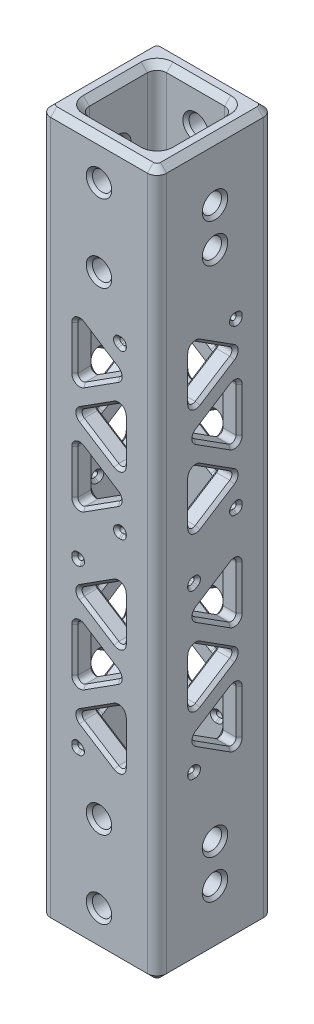
from build123d import *

# Parameters (mm, degrees)
SKETCH1_W                    = 19.05
SKETCH1_H                    = 19.05
SKETCH1_W_2                  = 12.7
SKETCH1_H_2                  = 12.7
BOSS_EXTRUDE1_DEPTH          = 57.94375
F_1_8_0_125_DIAMETER_HOLE1_D = 3.175
F_1_8_0_125_DIAMETER_HOLE2_D = 3.175
F_1_8_0_125_DIAMETER_HOLE3_D = 3.175
CUT_EXTRUDE1_DEPTH           = 10.525
CIRPATTERN2_COUNT            = 4
FILLET1_R                    = 1.5875
FILLET2_R                    = 0.79375
FILLET3_R                    = 0.396875
CHAMFER1_SIZE                = 1.016
CHAMFER2_SIZE                = 0.508


with BuildPart() as part:
    # Sketch1 → Boss-Extrude1 (new body, symmetric)
    with BuildSketch(Plane(origin=(0, 0, 0), x_dir=(1, 0, 0), z_dir=(0, 1, 0))):
        Rectangle(SKETCH1_W, SKETCH1_H)
        Rectangle(SKETCH1_W_2, SKETCH1_H_2, mode=Mode.SUBTRACT)
    extrude(amount=BOSS_EXTRUDE1_DEPTH, both=True)

    # 1_8 _0.125_ Diameter Hole1 (through all)
    with Locations(Plane(origin=(0, 0, 9.525), x_dir=(-1, 0, 0), z_dir=(0, 0, 1))):
        with Locations((0, -51.59375), (0, -38.89375), (0, 38.89375), (0, 51.59375)):
            Hole(F_1_8_0_125_DIAMETER_HOLE1_D / 2)

    # 1_8 _0.125_ Diameter Hole2 (through all)
    with Locations(Plane.ZY.offset(9.525)):
        with Locations((0, 48.41875), (0, 42.06875)):
            Hole(F_1_8_0_125_DIAMETER_HOLE2_D / 2)

    # 1_8 _0.125_ Diameter Hole3 (through all)
    with Locations(Plane(origin=(9.525, 0, 0), x_dir=(0, 0, -1), z_dir=(1, 0, 0))):
        with Locations((0, -42.06875), (0, -48.41875)):
            Hole(F_1_8_0_125_DIAMETER_HOLE3_D / 2)

    # Sketch14 → Cut-Extrude1 (cut, through all)
    with BuildSketch(Plane.XY):
        Polygon((-3.96875, 30.95625), (-1.935718061, 30.95625), (-3.96875, 29.659612075), align=None)
        Polygon((3.96875, 30.95625), (-3.96875, 25.893829025), (3.96875, 20.83140805), align=None)
        Polygon((-3.96875, 22.128045975), (3.96875, 17.065625), (-3.96875, 12.003204025), align=None)
        Polygon((3.96875, 13.29984195), (-3.96875, 8.237420975), (3.96875, 3.175), align=None)
        Polygon((-1.935718061, 3.175), (-3.96875, 3.175), (-3.96875, 4.471637925), align=None)
        Polygon((1.935718061, -3.175), (3.96875, -3.175), (3.96875, -4.471637925), align=None)
        Polygon((-3.96875, -3.175), (3.96875, -8.237420975), (-3.96875, -13.29984195), align=None)
        Polygon((3.96875, -12.003204025), (-3.96875, -17.065625), (3.96875, -22.128045975), align=None)
        Polygon((-3.96875, -30.95625), (3.96875, -25.893829025), (-3.96875, -20.83140805), align=None)
        Polygon((1.935718061, -30.95625), (3.96875, -30.95625), (3.96875, -29.659612075), align=None)
    cut_extrude1 = extrude(amount=-CUT_EXTRUDE1_DEPTH, mode=Mode.SUBTRACT)

    # CirPattern2: Cut-Extrude1 ×4 about axis
    cirpattern2_axis = Axis((0, 0, 0), (0, 1, 0))
    for i in range(1, CIRPATTERN2_COUNT):
        add(cut_extrude1.rotate(cirpattern2_axis, i * 360 / CIRPATTERN2_COUNT), mode=Mode.SUBTRACT)

    # Fillet1
    fillet1_edges = [part.edges().sort_by_distance(p)[0] for p in [
        (6.35, 0, 6.35),
        (6.35, 0, -6.35),
        (-6.35, 0, -6.35),
        (-6.35, 0, 6.35),
        (9.525, 0, 9.525),
        (-9.525, 0, 9.525),
        (-9.525, 0, -9.525),
        (9.525, 0, -9.525),
    ]]
    fillet(fillet1_edges, radius=FILLET1_R)

    # Fillet2
    fillet2_edges = [part.edges().sort_by_distance(p)[0] for p in [
        (3.96875, 30.95625, -7.9375),
        (3.96875, 20.83140805, -7.9375),
        (-3.96875, 25.893829025, -7.9375),
        (-3.96875, 12.003204025, -7.9375),
        (-3.96875, 22.128045975, -7.9375),
        (3.96875, 17.065625, -7.9375),
        (-3.96875, -13.29984195, -7.9375),
        (-3.96875, -3.175, -7.9375),
        (3.96875, -8.237420975, -7.9375),
        (3.96875, 13.29984195, -7.9375),
        (3.96875, 3.175, -7.9375),
        (-3.96875, 8.237420975, -7.9375),
        (-3.96875, -30.95625, -7.9375),
        (-3.96875, -20.83140805, -7.9375),
        (3.96875, -25.893829025, -7.9375),
        (3.96875, -12.003204025, -7.9375),
        (3.96875, -22.128045975, -7.9375),
        (-3.96875, -17.065625, -7.9375),
        (7.9375, -12.003204025, 3.96875),
        (-7.9375, -13.29984195, 3.96875),
        (7.9375, -13.29984195, -3.96875),
        (7.9375, -30.95625, -3.96875),
        (-7.9375, -12.003204025, -3.96875),
        (-7.9375, -30.95625, 3.96875),
        (7.9375, -22.128045975, 3.96875),
        (7.9375, -17.065625, -3.96875),
        (3.96875, -30.95625, 7.9375),
        (3.96875, -20.83140805, 7.9375),
        (-3.96875, -25.893829025, 7.9375),
        (3.96875, -13.29984195, 7.9375),
        (3.96875, -3.175, 7.9375),
        (-3.96875, -8.237420975, 7.9375),
        (7.9375, -20.83140805, -3.96875),
        (7.9375, -25.893829025, 3.96875),
        (7.9375, -3.175, -3.96875),
        (7.9375, -8.237420975, 3.96875),
        (-3.96875, -12.003204025, 7.9375),
        (-3.96875, -22.128045975, 7.9375),
        (3.96875, -17.065625, 7.9375),
        (-7.9375, -20.83140805, 3.96875),
        (-7.9375, -25.893829025, -3.96875),
        (-7.9375, -22.128045975, -3.96875),
        (-7.9375, -17.065625, 3.96875),
        (-7.9375, -3.175, 3.96875),
        (-7.9375, -8.237420975, -3.96875),
        (7.9375, 12.003204025, -3.96875),
        (-7.9375, 13.29984195, -3.96875),
        (7.9375, 13.29984195, 3.96875),
        (7.9375, 30.95625, 3.96875),
        (-7.9375, 30.95625, -3.96875),
        (-7.9375, 12.003204025, 3.96875),
        (7.9375, 3.175, 3.96875),
        (7.9375, 8.237420975, -3.96875),
        (-3.96875, 13.29984195, 7.9375),
        (-3.96875, 3.175, 7.9375),
        (3.96875, 8.237420975, 7.9375),
        (-3.96875, 30.95625, 7.9375),
        (-3.96875, 20.83140805, 7.9375),
        (3.96875, 25.893829025, 7.9375),
        (-7.9375, 20.83140805, -3.96875),
        (-7.9375, 25.893829025, 3.96875),
        (-7.9375, 22.128045975, 3.96875),
        (-7.9375, 17.065625, -3.96875),
        (3.96875, 12.003204025, 7.9375),
        (3.96875, 22.128045975, 7.9375),
        (-3.96875, 17.065625, 7.9375),
        (7.9375, 20.83140805, 3.96875),
        (7.9375, 25.893829025, -3.96875),
        (7.9375, 22.128045975, -3.96875),
        (7.9375, 17.065625, 3.96875),
        (-7.9375, 3.175, -3.96875),
        (-7.9375, 8.237420975, 3.96875),
    ]]
    fillet(fillet2_edges, radius=FILLET2_R)

    # Fillet3
    fillet3_edges = [part.edges().sort_by_distance(p)[0] for p in [
        (3.96875, -3.175, -7.9375),
        (3.96875, -4.471637925, -7.9375),
        (1.935718061, -3.175, -7.9375),
        (-3.96875, 3.175, -7.9375),
        (-3.96875, 4.471637925, -7.9375),
        (-1.935718061, 3.175, -7.9375),
        (3.96875, -29.659612075, -7.9375),
        (3.96875, -30.95625, -7.9375),
        (1.935718061, -30.95625, -7.9375),
        (-3.96875, 29.659612075, -7.9375),
        (-3.96875, 30.95625, -7.9375),
        (-1.935718061, 30.95625, -7.9375),
        (-7.9375, -29.659612075, -3.96875),
        (7.9375, -29.659612075, 3.96875),
        (7.9375, -30.95625, 1.935718061),
        (7.9375, -30.95625, 3.96875),
        (-7.9375, -3.175, -3.96875),
        (7.9375, -3.175, 3.96875),
        (7.9375, -4.471637925, 3.96875),
        (7.9375, -3.175, 1.935718061),
        (-7.9375, -4.471637925, -3.96875),
        (-7.9375, -3.175, -1.935718061),
        (-7.9375, -30.95625, -3.96875),
        (-7.9375, -30.95625, -1.935718061),
        (-3.96875, -3.175, 7.9375),
        (-3.96875, -4.471637925, 7.9375),
        (-1.935718061, -3.175, 7.9375),
        (-3.96875, -29.659612075, 7.9375),
        (-1.935718061, -30.95625, 7.9375),
        (-3.96875, -30.95625, 7.9375),
        (7.9375, 29.659612075, -3.96875),
        (7.9375, 3.175, -3.96875),
        (7.9375, 30.95625, -3.96875),
        (7.9375, 30.95625, -1.935718061),
        (3.96875, 3.175, 7.9375),
        (3.96875, 4.471637925, 7.9375),
        (1.935718061, 3.175, 7.9375),
        (-7.9375, 29.659612075, 3.96875),
        (-7.9375, 30.95625, 3.96875),
        (-7.9375, 30.95625, 1.935718061),
        (3.96875, 29.659612075, 7.9375),
        (3.96875, 30.95625, 7.9375),
        (1.935718061, 30.95625, 7.9375),
        (-7.9375, 3.175, 3.96875),
        (-7.9375, 4.471637925, 3.96875),
        (-7.9375, 3.175, 1.935718061),
        (7.9375, 4.471637925, -3.96875),
        (7.9375, 3.175, -1.935718061),
    ]]
    fillet(fillet3_edges, radius=FILLET3_R)

    # Chamfer1
    chamfer1_edges = [part.edges().sort_by_distance(p)[0] for p in [
        (0, -57.94375, -9.525),
        (0, 57.94375, -9.525),
        (9.525, -57.94375, 0),
        (0, -57.94375, 9.525),
        (-9.525, -57.94375, 0),
        (0, -57.94375, 6.35),
        (6.35, -57.94375, 0),
        (0, -57.94375, -6.35),
        (-6.35, -57.94375, 0),
        (-9.060032015, -57.94375, 9.060032015),
        (-9.060032015, -57.94375, -9.060032015),
        (9.060032015, -57.94375, 9.060032015),
        (9.060032015, -57.94375, -9.060032015),
        (9.525, 57.94375, 0),
        (-9.525, 57.94375, 0),
        (0, 57.94375, 9.525),
        (6.35, 57.94375, 0),
        (0, 57.94375, 6.35),
        (-6.35, 57.94375, 0),
        (0, 57.94375, -6.35),
        (-9.060032015, 57.94375, 9.060032015),
        (-9.060032015, 57.94375, -9.060032015),
        (9.060032015, 57.94375, 9.060032015),
        (9.060032015, 57.94375, -9.060032015),
        (5.885032015, -57.94375, -5.885032015),
        (5.885032015, 57.94375, -5.885032015),
        (5.885032015, -57.94375, 5.885032015),
        (5.885032015, 57.94375, 5.885032015),
        (-5.885032015, -57.94375, 5.885032015),
        (-5.885032015, 57.94375, 5.885032015),
        (-5.885032015, -57.94375, -5.885032015),
        (-5.885032015, 57.94375, -5.885032015),
    ]]
    chamfer(chamfer1_edges, length=CHAMFER1_SIZE)

    # Chamfer2
    chamfer2_edges = [part.edges().sort_by_distance(p)[0] for p in [
        (9.525, -12.548152991, -3.556607903),
        (6.35, 21.376357017, -3.556607903),
        (9.525, 21.376357017, -3.556607903),
        (6.35, 17.065625, 3.286382985),
        (9.525, 17.065625, 3.286382985),
        (6.35, 12.754892983, -3.556607903),
        (9.525, 12.754892983, -3.556607903),
        (6.35, 21.583097009, 3.556607903),
        (9.525, 21.583097009, 3.556607903),
        (6.35, 30.204561042, 3.556607903),
        (9.525, 30.204561042, 3.556607903),
        (6.35, 25.893829025, -3.286382985),
        (9.525, 25.893829025, -3.286382985),
        (3.556607903, -21.376357017, -6.35),
        (3.556607903, -21.376357017, -9.525),
        (-3.286382985, -17.065625, -6.35),
        (-3.286382985, -17.065625, -9.525),
        (3.556607903, -12.754892983, -6.35),
        (3.556607903, -12.754892983, -9.525),
        (-3.556607903, -21.583097009, -6.35),
        (-3.556607903, -21.583097009, -9.525),
        (3.286382985, -25.893829025, -6.35),
        (3.286382985, -25.893829025, -9.525),
        (-3.556607903, -30.204561042, -6.35),
        (-3.556607903, -30.204561042, -9.525),
        (3.556607903, 3.926688958, -6.35),
        (3.556607903, 3.926688958, -9.525),
        (-3.286382985, 8.237420975, -6.35),
        (-3.286382985, 8.237420975, -9.525),
        (3.556607903, 12.548152991, -6.35),
        (3.556607903, 12.548152991, -9.525),
        (-3.556607903, -3.926688958, -6.35),
        (-3.556607903, -3.926688958, -9.525),
        (3.286382985, -8.237420975, -6.35),
        (3.286382985, -8.237420975, -9.525),
        (-3.556607903, -12.548152991, -6.35),
        (-3.556607903, -12.548152991, -9.525),
        (-3.556607903, 21.376357017, -6.35),
        (-3.556607903, 21.376357017, -9.525),
        (3.286382985, 17.065625, -6.35),
        (3.286382985, 17.065625, -9.525),
        (-3.556607903, 12.754892983, -6.35),
        (-3.556607903, 12.754892983, -9.525),
        (3.556607903, 21.583097009, -6.35),
        (3.556607903, 21.583097009, -9.525),
        (3.556607903, 30.204561042, -6.35),
        (3.556607903, 30.204561042, -9.525),
        (-3.286382985, 25.893829025, -6.35),
        (-3.286382985, 25.893829025, -9.525),
        (-3.433961043, -30.95625, 6.35),
        (-3.433961043, -30.95625, 9.525),
        (-3.220550095, -30.136802991, 6.35),
        (-3.220550095, -30.136802991, 9.525),
        (-3.96875, -30.471415503, 6.35),
        (-3.96875, -30.471415503, 9.525),
        (-3.220550095, -3.994447009, 6.35),
        (-3.220550095, -3.994447009, 9.525),
        (-3.433961043, -3.175, 6.35),
        (-3.433961043, -3.175, 9.525),
        (-3.96875, -3.659834497, 6.35),
        (-3.96875, -3.659834497, 9.525),
        (3.220550095, 3.994447009, 6.35),
        (3.220550095, 3.994447009, 9.525),
        (3.433961043, 3.175, 6.35),
        (3.433961043, 3.175, 9.525),
        (3.96875, 3.659834497, 6.35),
        (3.96875, 3.659834497, 9.525),
        (3.220550095, 30.136802991, 6.35),
        (3.220550095, 30.136802991, 9.525),
        (3.96875, 30.471415503, 6.35),
        (3.96875, 30.471415503, 9.525),
        (3.433961043, 30.95625, 6.35),
        (3.433961043, 30.95625, 9.525),
        (-6.35, -30.95625, -3.433961043),
        (-9.525, -30.95625, -3.433961043),
        (-6.35, -30.136802991, -3.220550095),
        (-9.525, -30.136802991, -3.220550095),
        (-6.35, -30.471415503, -3.96875),
        (-9.525, -30.471415503, -3.96875),
        (-6.35, -3.994447009, -3.220550095),
        (-9.525, -3.994447009, -3.220550095),
        (-6.35, -3.175, -3.433961043),
        (-9.525, -3.175, -3.433961043),
        (-6.35, -3.659834497, -3.96875),
        (-9.525, -3.659834497, -3.96875),
        (-6.35, 3.175, 3.433961043),
        (-9.525, 3.175, 3.433961043),
        (-6.35, 3.659834497, 3.96875),
        (-9.525, 3.659834497, 3.96875),
        (-6.35, 3.994447009, 3.220550095),
        (-9.525, 3.994447009, 3.220550095),
        (-6.35, 30.95625, 3.433961043),
        (-9.525, 30.95625, 3.433961043),
        (-6.35, 30.136802991, 3.220550095),
        (-9.525, 30.136802991, 3.220550095),
        (-6.35, 30.471415503, 3.96875),
        (-9.525, 30.471415503, 3.96875),
        (6.35, 30.95625, -3.433961043),
        (9.525, 30.95625, -3.433961043),
        (6.35, 30.136802991, -3.220550095),
        (9.525, 30.136802991, -3.220550095),
        (6.35, 30.471415503, -3.96875),
        (9.525, 30.471415503, -3.96875),
        (6.35, -30.471415503, 3.96875),
        (9.525, -30.471415503, 3.96875),
        (6.35, -30.95625, 3.433961043),
        (9.525, -30.95625, 3.433961043),
        (6.35, -30.136802991, 3.220550095),
        (9.525, -30.136802991, 3.220550095),
        (6.35, 3.659834497, -3.96875),
        (9.525, 3.659834497, -3.96875),
        (6.35, 3.994447009, -3.220550095),
        (9.525, 3.994447009, -3.220550095),
        (6.35, 3.175, -3.433961043),
        (9.525, 3.175, -3.433961043),
        (6.35, -3.659834497, 3.96875),
        (9.525, -3.659834497, 3.96875),
        (6.35, -3.994447009, 3.220550095),
        (9.525, -3.994447009, 3.220550095),
        (6.35, -3.175, 3.433961043),
        (9.525, -3.175, 3.433961043),
        (-3.433961043, 30.95625, -6.35),
        (-3.433961043, 30.95625, -9.525),
        (-3.220550095, 30.136802991, -6.35),
        (-3.220550095, 30.136802991, -9.525),
        (-3.96875, 30.471415503, -6.35),
        (-3.96875, 30.471415503, -9.525),
        (3.96875, -30.471415503, -6.35),
        (3.96875, -30.471415503, -9.525),
        (3.433961043, -30.95625, -6.35),
        (3.433961043, -30.95625, -9.525),
        (3.220550095, -30.136802991, -6.35),
        (3.220550095, -30.136802991, -9.525),
        (-3.96875, 3.659834497, -6.35),
        (-3.96875, 3.659834497, -9.525),
        (-3.220550095, 3.994447009, -6.35),
        (-3.220550095, 3.994447009, -9.525),
        (-3.433961043, 3.175, -6.35),
        (-3.433961043, 3.175, -9.525),
        (3.96875, -3.659834497, -6.35),
        (3.96875, -3.659834497, -9.525),
        (3.220550095, -3.994447009, -6.35),
        (3.220550095, -3.994447009, -9.525),
        (3.433961043, -3.175, -6.35),
        (3.433961043, -3.175, -9.525),
        (-2.915055546, -30.670529004, 6.35),
        (-2.915055546, -30.670529004, 9.525),
        (-3.762678951, -30.035456554, 6.35),
        (-3.762678951, -30.035456554, 9.525),
        (-3.852508004, -30.840008004, 6.35),
        (-3.852508004, -30.840008004, 9.525),
        (-2.915055546, -3.460720996, 6.35),
        (-2.915055546, -3.460720996, 9.525),
        (-3.762678951, -4.095793446, 6.35),
        (-3.762678951, -4.095793446, 9.525),
        (-3.852508004, -3.291241996, 6.35),
        (-3.852508004, -3.291241996, 9.525),
        (2.915055546, 3.460720996, 6.35),
        (2.915055546, 3.460720996, 9.525),
        (3.762678951, 4.095793446, 6.35),
        (3.762678951, 4.095793446, 9.525),
        (3.852508004, 3.291241996, 6.35),
        (3.852508004, 3.291241996, 9.525),
        (3.762678951, 30.035456554, 6.35),
        (3.762678951, 30.035456554, 9.525),
        (3.852508004, 30.840008004, 6.35),
        (3.852508004, 30.840008004, 9.525),
        (2.915055546, 30.670529004, 6.35),
        (2.915055546, 30.670529004, 9.525),
        (-6.35, -30.670529004, -2.915055546),
        (-9.525, -30.670529004, -2.915055546),
        (-6.35, -30.035456554, -3.762678951),
        (-9.525, -30.035456554, -3.762678951),
        (-6.35, -30.840008004, -3.852508004),
        (-9.525, -30.840008004, -3.852508004),
        (-6.35, -3.460720996, -2.915055546),
        (-9.525, -3.460720996, -2.915055546),
        (-6.35, -4.095793446, -3.762678951),
        (-9.525, -4.095793446, -3.762678951),
        (-6.35, -3.291241996, -3.852508004),
        (-9.525, -3.291241996, -3.852508004),
        (-6.35, 3.291241996, 3.852508004),
        (-9.525, 3.291241996, 3.852508004),
        (-6.35, 4.095793446, 3.762678951),
        (-9.525, 4.095793446, 3.762678951),
        (-6.35, 3.460720996, 2.915055546),
        (-9.525, 3.460720996, 2.915055546),
        (-6.35, 30.670529004, 2.915055546),
        (-9.525, 30.670529004, 2.915055546),
        (-6.35, 30.035456554, 3.762678951),
        (-9.525, 30.035456554, 3.762678951),
        (-6.35, 30.840008004, 3.852508004),
        (-9.525, 30.840008004, 3.852508004),
        (6.35, 30.670529004, -2.915055546),
        (9.525, 30.670529004, -2.915055546),
        (6.35, 30.035456554, -3.762678951),
        (9.525, 30.035456554, -3.762678951),
        (6.35, -30.840008004, 3.852508004),
        (9.525, -30.840008004, 3.852508004),
        (6.35, -30.670529004, 2.915055546),
        (9.525, -30.670529004, 2.915055546),
        (6.35, -30.035456554, 3.762678951),
        (9.525, -30.035456554, 3.762678951),
        (6.35, 4.095793446, -3.762678951),
        (9.525, 4.095793446, -3.762678951),
        (6.35, 3.460720996, -2.915055546),
        (9.525, 3.460720996, -2.915055546),
        (6.35, 3.291241996, -3.852508004),
        (9.525, 3.291241996, -3.852508004),
        (6.35, -4.095793446, 3.762678951),
        (9.525, -4.095793446, 3.762678951),
        (6.35, -3.460720996, 2.915055546),
        (9.525, -3.460720996, 2.915055546),
        (6.35, -3.291241996, 3.852508004),
        (9.525, -3.291241996, 3.852508004),
        (6.35, 30.840008004, -3.852508004),
        (9.525, 30.840008004, -3.852508004),
        (-2.915055546, 30.670529004, -6.35),
        (-2.915055546, 30.670529004, -9.525),
        (-3.762678951, 30.035456554, -6.35),
        (-3.762678951, 30.035456554, -9.525),
        (3.852508004, -30.840008004, -6.35),
        (3.852508004, -30.840008004, -9.525),
        (2.915055546, -30.670529004, -6.35),
        (2.915055546, -30.670529004, -9.525),
        (3.762678951, -30.035456554, -6.35),
        (3.762678951, -30.035456554, -9.525),
        (-3.762678951, 4.095793446, -6.35),
        (-3.762678951, 4.095793446, -9.525),
        (-2.915055546, 3.460720996, -6.35),
        (-2.915055546, 3.460720996, -9.525),
        (-3.852508004, 3.291241996, -6.35),
        (-3.852508004, 3.291241996, -9.525),
        (3.762678951, -4.095793446, -6.35),
        (3.762678951, -4.095793446, -9.525),
        (2.915055546, -3.460720996, -6.35),
        (2.915055546, -3.460720996, -9.525),
        (3.852508004, -3.291241996, -6.35),
        (3.852508004, -3.291241996, -9.525),
        (-3.852508004, 30.840008004, -6.35),
        (-3.852508004, 30.840008004, -9.525),
        (-1.5875, -51.59375, -6.35),
        (-1.5875, -51.59375, 6.35),
        (-1.5875, -51.59375, 9.525),
        (-1.5875, -51.59375, -9.525),
        (-1.5875, -38.89375, -6.35),
        (-1.5875, -38.89375, 6.35),
        (-1.5875, -38.89375, 9.525),
        (-1.5875, -38.89375, -9.525),
        (-1.5875, 38.89375, -6.35),
        (-1.5875, 38.89375, 6.35),
        (-1.5875, 38.89375, 9.525),
        (-1.5875, 38.89375, -9.525),
        (-1.5875, 51.59375, -6.35),
        (-1.5875, 51.59375, 6.35),
        (-1.5875, 51.59375, 9.525),
        (-1.5875, 51.59375, -9.525),
        (6.35, 42.06875, 1.5875),
        (-6.35, 42.06875, 1.5875),
        (-9.525, 42.06875, 1.5875),
        (9.525, 42.06875, 1.5875),
        (6.35, 48.41875, 1.5875),
        (-6.35, 48.41875, 1.5875),
        (-9.525, 48.41875, 1.5875),
        (9.525, 48.41875, 1.5875),
        (-6.35, -23.417237444, -0.085638388),
        (-9.525, -23.417237444, -0.085638388),
        (-6.35, -28.370420606, -0.085638388),
        (-9.525, -28.370420606, -0.085638388),
        (-6.35, -25.893829025, 3.96875),
        (-9.525, -25.893829025, 3.96875),
        (-6.35, -14.589033419, 0.085638388),
        (-9.525, -14.589033419, 0.085638388),
        (-6.35, -17.065625, -3.96875),
        (-9.525, -17.065625, -3.96875),
        (-6.35, -19.542216581, 0.085638388),
        (-9.525, -19.542216581, 0.085638388),
        (-6.35, -10.714012556, -0.085638388),
        (-9.525, -10.714012556, -0.085638388),
        (-6.35, -8.237420975, 3.96875),
        (-9.525, -8.237420975, 3.96875),
        (-6.35, -5.760829394, -0.085638388),
        (-9.525, -5.760829394, -0.085638388),
        (-6.35, 10.714012556, 0.085638388),
        (-9.525, 10.714012556, 0.085638388),
        (-6.35, 8.237420975, -3.96875),
        (-9.525, 8.237420975, -3.96875),
        (-6.35, 5.760829394, 0.085638388),
        (-9.525, 5.760829394, 0.085638388),
        (-6.35, 14.589033419, -0.085638388),
        (-9.525, 14.589033419, -0.085638388),
        (-6.35, 17.065625, 3.96875),
        (-9.525, 17.065625, 3.96875),
        (-6.35, 19.542216581, -0.085638388),
        (-9.525, 19.542216581, -0.085638388),
        (-6.35, 28.370420606, 0.085638388),
        (-9.525, 28.370420606, 0.085638388),
        (-6.35, 25.893829025, -3.96875),
        (-9.525, 25.893829025, -3.96875),
        (-6.35, 23.417237444, 0.085638388),
        (-9.525, 23.417237444, 0.085638388),
        (-0.085638388, -28.370420606, 6.35),
        (-0.085638388, -28.370420606, 9.525),
        (3.96875, -25.893829025, 6.35),
        (3.96875, -25.893829025, 9.525),
        (-0.085638388, -23.417237444, 6.35),
        (-0.085638388, -23.417237444, 9.525),
        (0.085638388, -14.589033419, 6.35),
        (0.085638388, -14.589033419, 9.525),
        (-3.96875, -17.065625, 6.35),
        (-3.96875, -17.065625, 9.525),
        (0.085638388, -19.542216581, 6.35),
        (0.085638388, -19.542216581, 9.525),
        (-0.085638388, -10.714012556, 6.35),
        (-0.085638388, -10.714012556, 9.525),
        (3.96875, -8.237420975, 6.35),
        (3.96875, -8.237420975, 9.525),
        (-0.085638388, -5.760829394, 6.35),
        (-0.085638388, -5.760829394, 9.525),
        (0.085638388, 10.714012556, 6.35),
        (0.085638388, 10.714012556, 9.525),
        (-3.96875, 8.237420975, 6.35),
        (-3.96875, 8.237420975, 9.525),
        (0.085638388, 5.760829394, 6.35),
        (0.085638388, 5.760829394, 9.525),
        (-0.085638388, 19.542216581, 6.35),
        (-0.085638388, 19.542216581, 9.525),
        (-0.085638388, 14.589033419, 6.35),
        (-0.085638388, 14.589033419, 9.525),
        (3.96875, 17.065625, 6.35),
        (3.96875, 17.065625, 9.525),
        (0.085638388, 23.417237444, 6.35),
        (0.085638388, 23.417237444, 9.525),
        (0.085638388, 28.370420606, 6.35),
        (0.085638388, 28.370420606, 9.525),
        (-3.96875, 25.893829025, 6.35),
        (-3.96875, 25.893829025, 9.525),
        (6.35, -17.065625, 3.96875),
        (9.525, -17.065625, 3.96875),
        (6.35, -19.542216581, -0.085638388),
        (9.525, -19.542216581, -0.085638388),
        (6.35, -14.589033419, -0.085638388),
        (9.525, -14.589033419, -0.085638388),
        (6.35, -25.893829025, -3.96875),
        (9.525, -25.893829025, -3.96875),
        (6.35, -23.417237444, 0.085638388),
        (9.525, -23.417237444, 0.085638388),
        (6.35, -28.370420606, 0.085638388),
        (9.525, -28.370420606, 0.085638388),
        (6.35, 8.237420975, 3.96875),
        (9.525, 8.237420975, 3.96875),
        (6.35, 5.760829394, -0.085638388),
        (9.525, 5.760829394, -0.085638388),
        (6.35, 10.714012556, -0.085638388),
        (9.525, 10.714012556, -0.085638388),
        (6.35, -48.41875, -1.5875),
        (-6.35, -48.41875, -1.5875),
        (6.35, -8.237420975, -3.96875),
        (9.525, -8.237420975, -3.96875),
        (-9.525, -48.41875, -1.5875),
        (9.525, -48.41875, -1.5875),
        (6.35, -5.760829394, 0.085638388),
        (9.525, -5.760829394, 0.085638388),
        (6.35, -10.714012556, 0.085638388),
        (9.525, -10.714012556, 0.085638388),
        (6.35, 17.065625, -3.96875),
        (9.525, 17.065625, -3.96875),
        (6.35, 19.542216581, 0.085638388),
        (9.525, 19.542216581, 0.085638388),
        (6.35, 14.589033419, 0.085638388),
        (9.525, 14.589033419, 0.085638388),
        (6.35, 25.893829025, 3.96875),
        (9.525, 25.893829025, 3.96875),
        (6.35, 23.417237444, -0.085638388),
        (9.525, 23.417237444, -0.085638388),
        (6.35, 28.370420606, -0.085638388),
        (9.525, 28.370420606, -0.085638388),
        (3.96875, -17.065625, -6.35),
        (3.96875, -17.065625, -9.525),
        (-0.085638388, -19.542216581, -6.35),
        (-0.085638388, -19.542216581, -9.525),
        (-0.085638388, -14.589033419, -6.35),
        (-0.085638388, -14.589033419, -9.525),
        (-3.96875, -25.893829025, -6.35),
        (-3.96875, -25.893829025, -9.525),
        (0.085638388, -23.417237444, -6.35),
        (0.085638388, -23.417237444, -9.525),
        (0.085638388, -28.370420606, -6.35),
        (0.085638388, -28.370420606, -9.525),
        (3.96875, 8.237420975, -6.35),
        (3.96875, 8.237420975, -9.525),
        (-0.085638388, 5.760829394, -6.35),
        (-0.085638388, 5.760829394, -9.525),
        (-0.085638388, 10.714012556, -6.35),
        (-0.085638388, 10.714012556, -9.525),
        (-3.96875, -8.237420975, -6.35),
        (-3.96875, -8.237420975, -9.525),
        (0.085638388, -5.760829394, -6.35),
        (0.085638388, -5.760829394, -9.525),
        (0.085638388, -10.714012556, -6.35),
        (0.085638388, -10.714012556, -9.525),
        (-3.96875, 17.065625, -6.35),
        (-3.96875, 17.065625, -9.525),
        (0.085638388, 19.542216581, -6.35),
        (0.085638388, 19.542216581, -9.525),
        (0.085638388, 14.589033419, -6.35),
        (0.085638388, 14.589033419, -9.525),
        (3.96875, 25.893829025, -6.35),
        (3.96875, 25.893829025, -9.525),
        (-0.085638388, 23.417237444, -6.35),
        (-0.085638388, 23.417237444, -9.525),
        (-0.085638388, 28.370420606, -6.35),
        (-0.085638388, 28.370420606, -9.525),
        (-6.35, -25.893829025, -3.286382985),
        (-9.525, -25.893829025, -3.286382985),
        (-6.35, -21.583097009, 3.556607903),
        (-9.525, -21.583097009, 3.556607903),
        (-6.35, -30.204561042, 3.556607903),
        (-9.525, -30.204561042, 3.556607903),
        (-6.35, -12.754892983, -3.556607903),
        (-9.525, -12.754892983, -3.556607903),
        (-6.35, -21.376357017, -3.556607903),
        (-9.525, -21.376357017, -3.556607903),
        (-6.35, -17.065625, 3.286382985),
        (-9.525, -17.065625, 3.286382985),
        (-6.35, -12.548152991, 3.556607903),
        (-9.525, -12.548152991, 3.556607903),
        (-6.35, -3.926688958, 3.556607903),
        (-9.525, -3.926688958, 3.556607903),
        (-6.35, -8.237420975, -3.286382985),
        (-9.525, -8.237420975, -3.286382985),
        (-6.35, 12.548152991, -3.556607903),
        (-9.525, 12.548152991, -3.556607903),
        (-6.35, 3.926688958, -3.556607903),
        (-9.525, 3.926688958, -3.556607903),
        (-6.35, 8.237420975, 3.286382985),
        (-9.525, 8.237420975, 3.286382985),
        (-6.35, 12.754892983, 3.556607903),
        (-9.525, 12.754892983, 3.556607903),
        (-6.35, 21.376357017, 3.556607903),
        (-9.525, 21.376357017, 3.556607903),
        (-6.35, 17.065625, -3.286382985),
        (-9.525, 17.065625, -3.286382985),
        (-6.35, 30.204561042, -3.556607903),
        (-9.525, 30.204561042, -3.556607903),
        (-6.35, 21.583097009, -3.556607903),
        (-9.525, 21.583097009, -3.556607903),
        (-6.35, 25.893829025, 3.286382985),
        (-9.525, 25.893829025, 3.286382985),
        (3.556607903, -30.204561042, 6.35),
        (3.556607903, -30.204561042, 9.525),
        (6.35, -42.06875, -1.5875),
        (3.556607903, -21.583097009, 6.35),
        (3.556607903, -21.583097009, 9.525),
        (-6.35, -42.06875, -1.5875),
        (-3.286382985, -25.893829025, 6.35),
        (-3.286382985, -25.893829025, 9.525),
        (-3.556607903, -12.754892983, 6.35),
        (-9.525, -42.06875, -1.5875),
        (-3.556607903, -12.754892983, 9.525),
        (-3.556607903, -21.376357017, 6.35),
        (9.525, -42.06875, -1.5875),
        (-3.556607903, -21.376357017, 9.525),
        (3.286382985, -17.065625, 6.35),
        (3.286382985, -17.065625, 9.525),
        (3.556607903, -12.548152991, 6.35),
        (3.556607903, -12.548152991, 9.525),
        (3.556607903, -3.926688958, 6.35),
        (3.556607903, -3.926688958, 9.525),
        (-3.286382985, -8.237420975, 6.35),
        (-3.286382985, -8.237420975, 9.525),
        (-3.556607903, 12.548152991, 6.35),
        (-3.556607903, 12.548152991, 9.525),
        (-3.556607903, 3.926688958, 6.35),
        (-3.556607903, 3.926688958, 9.525),
        (3.286382985, 8.237420975, 6.35),
        (3.286382985, 8.237420975, 9.525),
        (-3.286382985, 17.065625, 6.35),
        (-3.286382985, 17.065625, 9.525),
        (3.556607903, 12.754892983, 6.35),
        (3.556607903, 12.754892983, 9.525),
        (3.556607903, 21.376357017, 6.35),
        (3.556607903, 21.376357017, 9.525),
        (3.286382985, 25.893829025, 6.35),
        (3.286382985, 25.893829025, 9.525),
        (-3.556607903, 30.204561042, 6.35),
        (-3.556607903, 30.204561042, 9.525),
        (-3.556607903, 21.583097009, 6.35),
        (-3.556607903, 21.583097009, 9.525),
        (6.35, -21.376357017, 3.556607903),
        (9.525, -21.376357017, 3.556607903),
        (6.35, -17.065625, -3.286382985),
        (9.525, -17.065625, -3.286382985),
        (6.35, -12.754892983, 3.556607903),
        (9.525, -12.754892983, 3.556607903),
        (6.35, -21.583097009, -3.556607903),
        (9.525, -21.583097009, -3.556607903),
        (6.35, -25.893829025, 3.286382985),
        (9.525, -25.893829025, 3.286382985),
        (6.35, -30.204561042, -3.556607903),
        (9.525, -30.204561042, -3.556607903),
        (6.35, 3.926688958, 3.556607903),
        (9.525, 3.926688958, 3.556607903),
        (6.35, 8.237420975, -3.286382985),
        (9.525, 8.237420975, -3.286382985),
        (6.35, 12.548152991, 3.556607903),
        (9.525, 12.548152991, 3.556607903),
        (6.35, -3.926688958, -3.556607903),
        (9.525, -3.926688958, -3.556607903),
        (6.35, -8.237420975, 3.286382985),
        (9.525, -8.237420975, 3.286382985),
        (6.35, -12.548152991, -3.556607903),
    ]]
    chamfer(chamfer2_edges, length=CHAMFER2_SIZE)


solid = part.part
